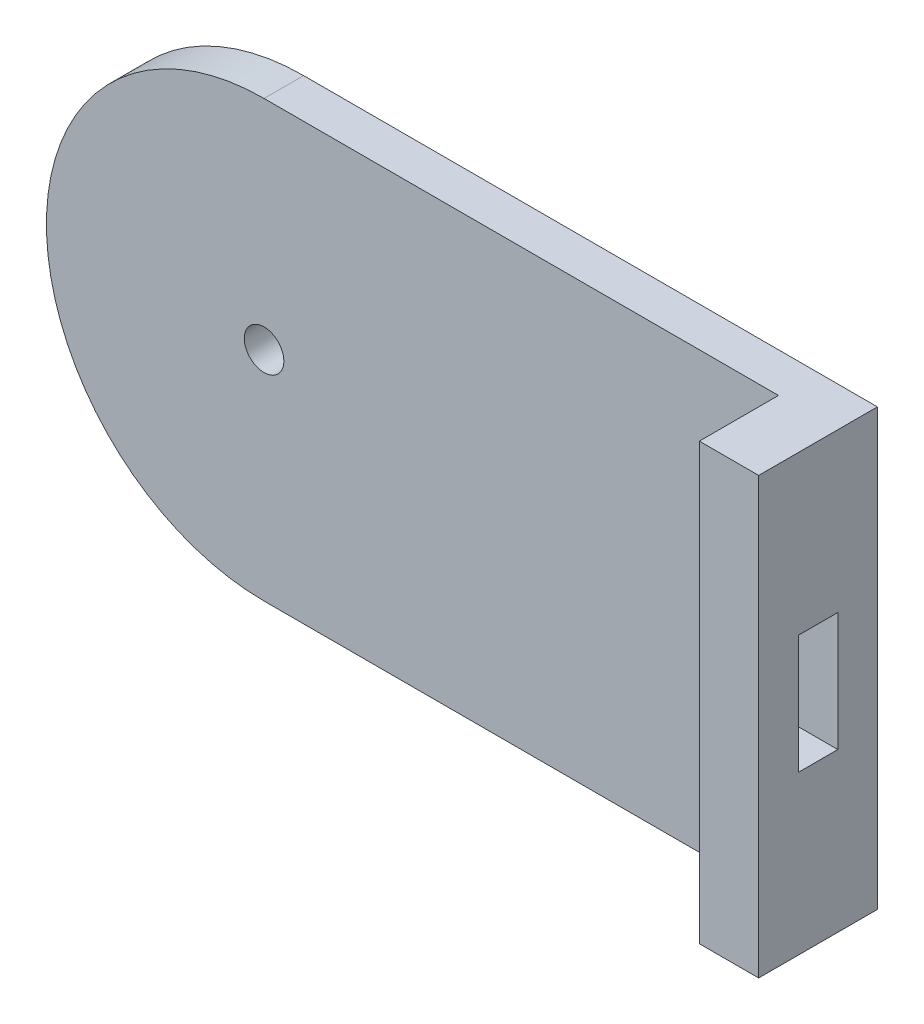
from build123d import *

# Parameters (mm, degrees)
SKETCH1_R           = 5
BOSS_EXTRUDE1_DEPTH = 10
SKETCH1_3_W         = 15
SKETCH1_3_H         = 110
BOSS_EXTRUDE2_DEPTH = 20
SKETCH2_W           = 10
SKETCH2_H           = 30
CUT_EXTRUDE1_DEPTH  = 20


with BuildPart() as part:
    # Sketch1 → Boss-Extrude1 (new body)
    with BuildSketch(Plane.XY):
        with BuildLine():
            ThreePointArc((-59.818461348, 27.177394162), (-114.818461348, -27.822605838), (-59.818461348, -82.822605838))
            Line((-59.818461348, -82.822605838), (85.181538652, -82.822605838))
            Line((85.181538652, -82.822605838), (85.181538652, 27.177394162))
            Line((85.181538652, 27.177394162), (-59.818461348, 27.177394162))
        make_face()
        with Locations((-59.818461348, -27.822605838)):
            Circle(SKETCH1_R, mode=Mode.SUBTRACT)
    extrude(amount=-BOSS_EXTRUDE1_DEPTH)

    # Sketch1_3 → Boss-Extrude2 (add)
    with BuildSketch(Plane.XY):
        with Locations((77.681538652, -27.822605838)):
            Rectangle(SKETCH1_3_W, SKETCH1_3_H)
    extrude(amount=BOSS_EXTRUDE2_DEPTH)

    # Sketch2 → Cut-Extrude1 (cut)
    with BuildSketch(Plane(origin=(85.181538652, 0, 0), x_dir=(0, 0, -1), z_dir=(1, 0, 0))):
        with Locations((-5, -27.822605838)):
            Rectangle(SKETCH2_W, SKETCH2_H)
    extrude(amount=-CUT_EXTRUDE1_DEPTH, mode=Mode.SUBTRACT)


solid = part.part
